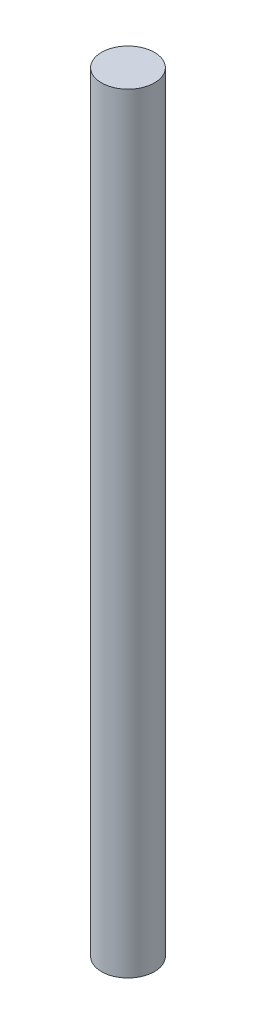
from build123d import *

# Parameters (mm, degrees)
SKETCH1_R           = 11
BOSS_EXTRUDE1_DEPTH = 320


with BuildPart() as part:
    # Sketch1 → Boss-Extrude1 (new body)
    with BuildSketch(Plane(origin=(0, 0, 0), x_dir=(1, 0, 0), z_dir=(0, 1, 0))):
        Circle(SKETCH1_R)
    extrude(amount=BOSS_EXTRUDE1_DEPTH)


solid = part.part
